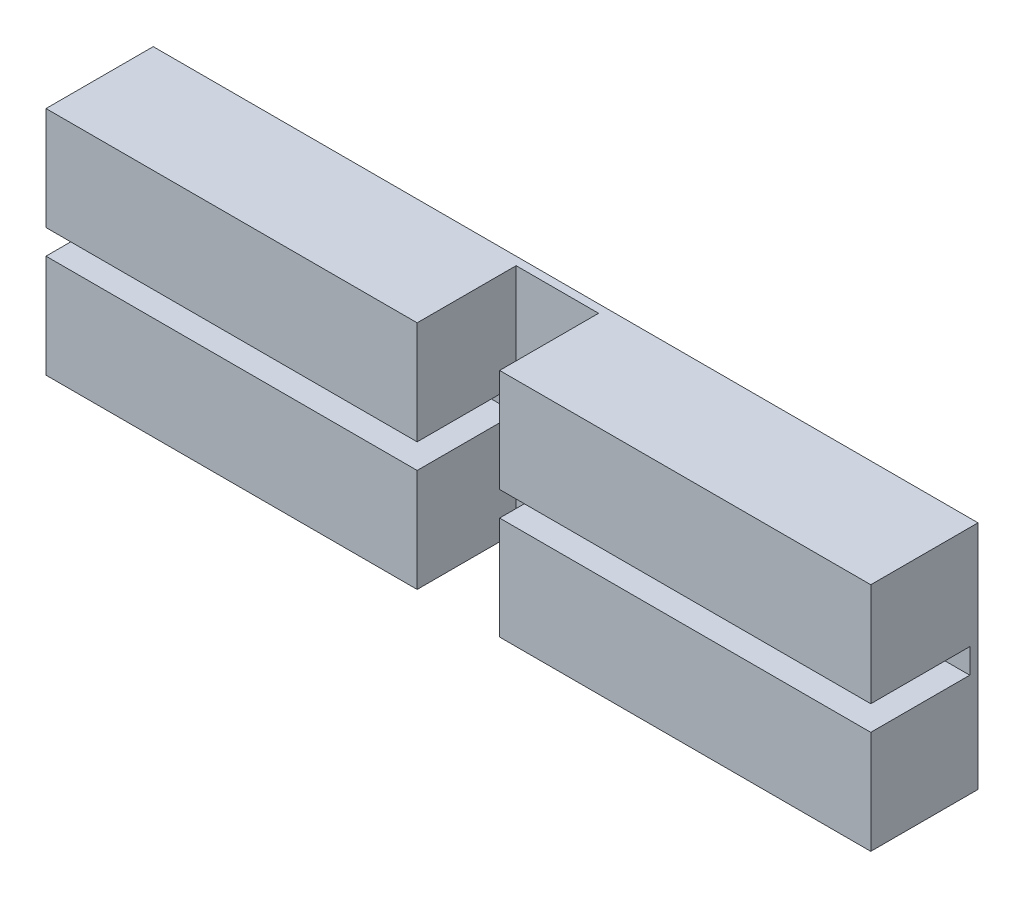
from build123d import *

# Parameters (mm, degrees)
SKETCH_1_W          = 20
SKETCH_1_H          = 5.6
EXTRUDE_1_DEPTH     = 2.6
SKETCH_2_W          = 2.4
SKETCH_2_H          = 0.6
CUT_EXTRUDE_1_DEPTH = 21
SKETCH_3_W          = 2
SKETCH_3_H          = 2.4
CUT_EXTRUDE_2_DEPTH = 6.6


with BuildPart() as part:
    # 草图1 → 凸台-拉伸1 (new body)
    with BuildSketch(Plane.XY):
        Rectangle(SKETCH_1_W, SKETCH_1_H)
    extrude(amount=EXTRUDE_1_DEPTH)

    # 草图2 → 切除-拉伸1 (cut, through all)
    with BuildSketch(Plane(origin=(10, 0, 0), x_dir=(0, 0, -1), z_dir=(1, 0, 0))):
        with Locations((-1.4, 0)):
            Rectangle(SKETCH_2_W, SKETCH_2_H)
    extrude(amount=-CUT_EXTRUDE_1_DEPTH, mode=Mode.SUBTRACT)

    # 草图3 → 切除-拉伸2 (cut, through all)
    with BuildSketch(Plane.XZ.offset(2.8)):
        with Locations((0, 1.4)):
            Rectangle(SKETCH_3_W, SKETCH_3_H)
    extrude(amount=-CUT_EXTRUDE_2_DEPTH, mode=Mode.SUBTRACT)


solid = part.part
